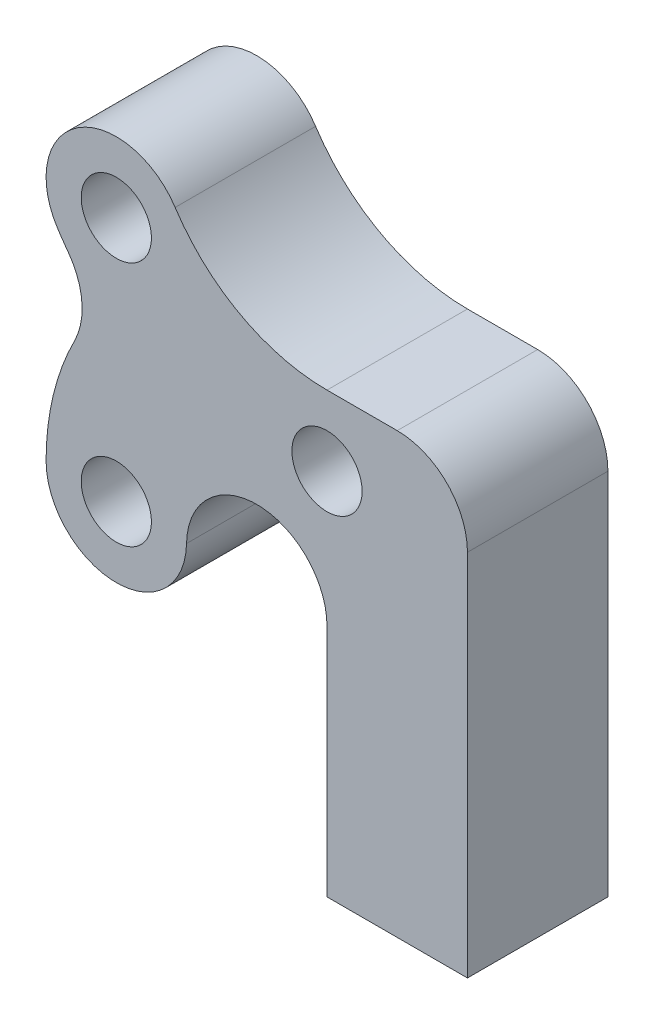
from build123d import *

# Parameters (mm, degrees)
ESQUISSE1_R             = 2
BOSS_EXTRU_1_DEPTH      = 8
ESQUISSE2_R             = 2
ENL_V_MAT_EXTRU_1_DEPTH = 20
CONG_1_R                = 4


with BuildPart() as part:
    # Esquisse1 → Boss.-Extru.1 (new body)
    with BuildSketch(Plane.XY):
        with BuildLine():
            Line((14.823672032, -22.72937471), (6.823672032, -22.72937471))
            Line((6.823672032, -22.72937471), (6.823672032, -5.72937471))
            ThreePointArc((6.823672032, -5.72937471), (3.664545235, -5.455042233), (0.599995261, -4.640257669))
            ThreePointArc((0.599995261, -4.640257669), (-0.7167539, -6.768921529), (-1.176327968, -9.22937471))
            ThreePointArc((-1.176327968, -9.22937471), (-5.176327968, -13.22937471), (-9.176327968, -9.22937471))
            ThreePointArc((-9.176327968, -9.22937471), (-8.40967046, -4.525117147), (-6.189038967, -0.307701027))
            ThreePointArc((-6.189038967, -0.307701027), (-7.431435725, 1.079388257), (-8.526663538, 2.58539039))
            ThreePointArc((-8.526663538, 2.58539039), (-7.361562867, 8.12096086), (-1.825992398, 6.955860189))
            ThreePointArc((-1.825992398, 6.955860189), (1.905132594, 3.517167866), (6.823672032, 2.27062529))
            Line((6.823672032, 2.27062529), (14.823672032, 2.27062529))
            Line((14.823672032, 2.27062529), (14.823672032, -22.72937471))
        make_face()
        with Locations((-5.176327968, 4.77062529)):
            Circle(ESQUISSE1_R, mode=Mode.SUBTRACT)
        with Locations((6.823672032, -1.72937471)):
            Circle(ESQUISSE1_R, mode=Mode.SUBTRACT)
        with Locations((-5.176327968, -9.22937471)):
            Circle(ESQUISSE1_R, mode=Mode.SUBTRACT)
    extrude(amount=BOSS_EXTRU_1_DEPTH)

    # Esquisse2 → Enlèv. mat.-Extru.1 (cut)
    with BuildSketch(Plane.XZ.offset(22.72937471)):
        with Locations((10.823672032, 4)):
            Circle(ESQUISSE2_R)
    extrude(amount=-ENL_V_MAT_EXTRU_1_DEPTH, mode=Mode.SUBTRACT)

    # Congé1
    cong_1_edges = [part.edges().sort_by_distance(p)[0] for p in [
        (-6.189038967, -0.307701027, 4),
        (0.599995261, -4.640257669, 4),
        (6.823672032, -5.72937471, 4),
        (14.823672032, 2.27062529, 4),
    ]]
    fillet(cong_1_edges, radius=CONG_1_R)


solid = part.part
